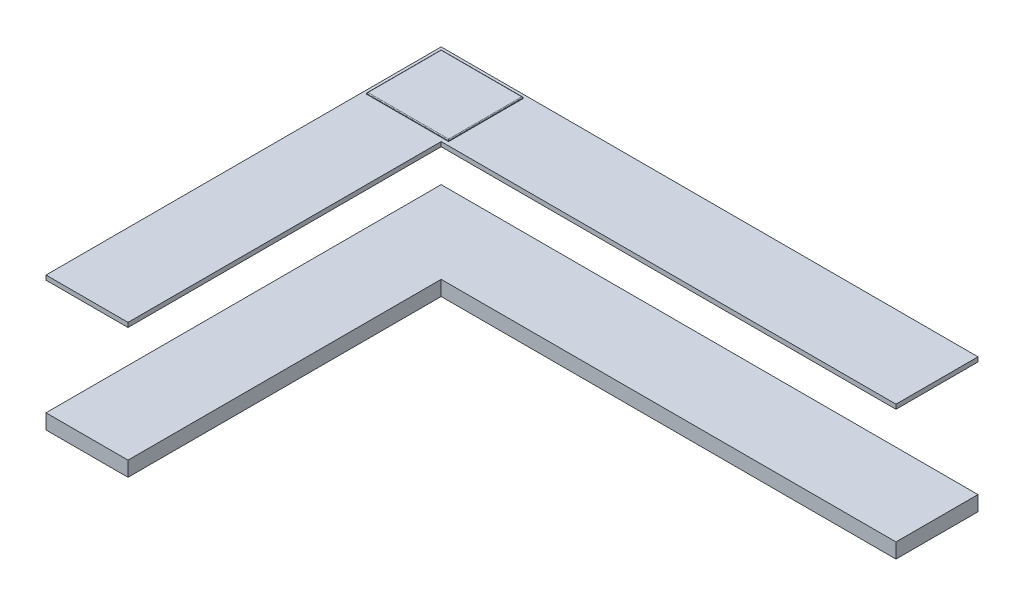
from build123d import *

# Parameters (mm, degrees)
BOSS_EXTRUDE1_DEPTH = 100
BOSS_EXTRUDE8_DEPTH = 30
SKETCH13_W          = 1
SKETCH13_H          = 1
CUT_EXTRUDE1_DEPTH  = 30
SKETCH14_W          = 550
SKETCH14_H          = 500
BOSS_EXTRUDE9_DEPTH = 10
FILLET1_R           = 5


with BuildPart() as part:
    # Sketch1 → Boss-Extrude1 (new body)
    with BuildSketch(Plane(origin=(0, 0, 0), x_dir=(1, 0, 0), z_dir=(0, 1, 0))):
        Polygon((2163.694267516, 907.877525978), (-1436.305732484, 907.877525978), (-1436.305732484, -1742.122474022), (-886.305732484, -1742.122474022), (-886.305732484, 357.877525978), (2163.694267516, 357.877525978), align=None)
    extrude(amount=BOSS_EXTRUDE1_DEPTH)


with BuildPart() as body_2:
    # Sketch11 → Boss-Extrude8 (new body)
    with BuildSketch(Plane(origin=(0, 870, 0), x_dir=(1, 0, 0), z_dir=(0, 1, 0))):
        Polygon((-886.305732484, 357.877525978), (-886.305732484, -1742.122474022), (-1436.305732484, -1742.122474022), (-1436.305732484, 907.877525978), (2163.694267516, 907.877525978), (2163.694267516, 357.877525978), align=None)
    extrude(amount=BOSS_EXTRUDE8_DEPTH)

    # Sketch13 → Cut-Extrude1 (cut)
    with BuildSketch(Plane(origin=(0, 900, 0), x_dir=(1, 0, 0), z_dir=(0, 1, 0))):
        with Locations((-911.805732484, -1241.622474022)):
            Rectangle(SKETCH13_W, SKETCH13_H)
        with Locations((1763.194267516, 383.377525978)):
            Rectangle(SKETCH13_W, SKETCH13_H)
    extrude(amount=-CUT_EXTRUDE1_DEPTH, mode=Mode.SUBTRACT)

    # Sketch14 → Boss-Extrude9 (add)
    with BuildSketch(Plane(origin=(0, 900, 0), x_dir=(1, 0, 0), z_dir=(0, 1, 0))):
        with Locations((-1136.305732484, 632.877525978)):
            Rectangle(SKETCH14_W, SKETCH14_H)
    extrude(amount=BOSS_EXTRUDE9_DEPTH)

    # Fillet1
    fillet1_edges = [body_2.edges().sort_by_distance(p)[0] for p in [
        (-1411.305732484, 910, -632.877525978),
        (-1136.305732484, 910, -382.877525978),
        (-861.305732484, 910, -632.877525978),
        (-1136.305732484, 910, -882.877525978),
    ]]
    fillet(fillet1_edges, radius=FILLET1_R)


solid = Compound([part.part, body_2.part])
